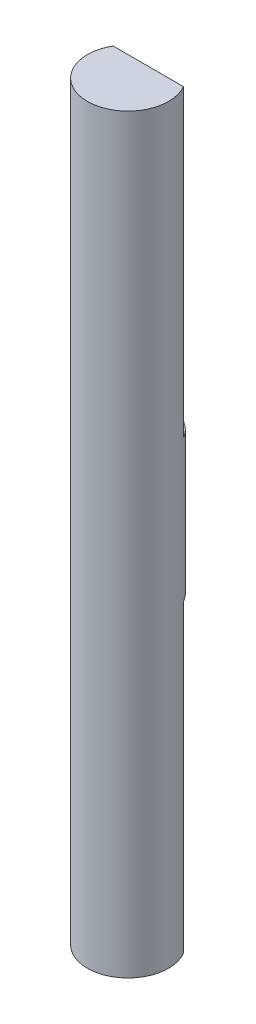
from build123d import *

# Parameters (mm, degrees)
BOSS_EXTRUDE1_DEPTH      = 37
BOSS_EXTRUDE1_DEPTH_BACK = 37
SKETCH1_R                = 4
CUT_EXTRUDE1_DEPTH       = 30


with BuildPart() as part:
    # Sketch1 → Boss-Extrude1 (new, two sides: drawn at the far end of the back side and taken through both)
    with BuildSketch(Plane(origin=(0, 0, 0), x_dir=(1, 0, 0), z_dir=(0, 1, 0)).offset(-BOSS_EXTRUDE1_DEPTH_BACK)):
        Circle(SKETCH1_R)
    extrude(amount=BOSS_EXTRUDE1_DEPTH + BOSS_EXTRUDE1_DEPTH_BACK)

    # Sketch2 → Cut-Extrude1 (cut)
    with BuildSketch(Plane(origin=(0, 37, 0), x_dir=(1, 0, 0), z_dir=(0, 1, 0))):
        with BuildLine():
            ThreePointArc((3.464101615, 2), (0, 4), (-3.464101615, 2))
            Line((-3.464101615, 2), (3.464101615, 2))
        make_face()
    cut_extrude1 = extrude(amount=-CUT_EXTRUDE1_DEPTH, mode=Mode.SUBTRACT)

    # Mirror1: Cut-Extrude1 across plane
    add(cut_extrude1.mirror(Plane.ZX), mode=Mode.SUBTRACT)


solid = part.part
